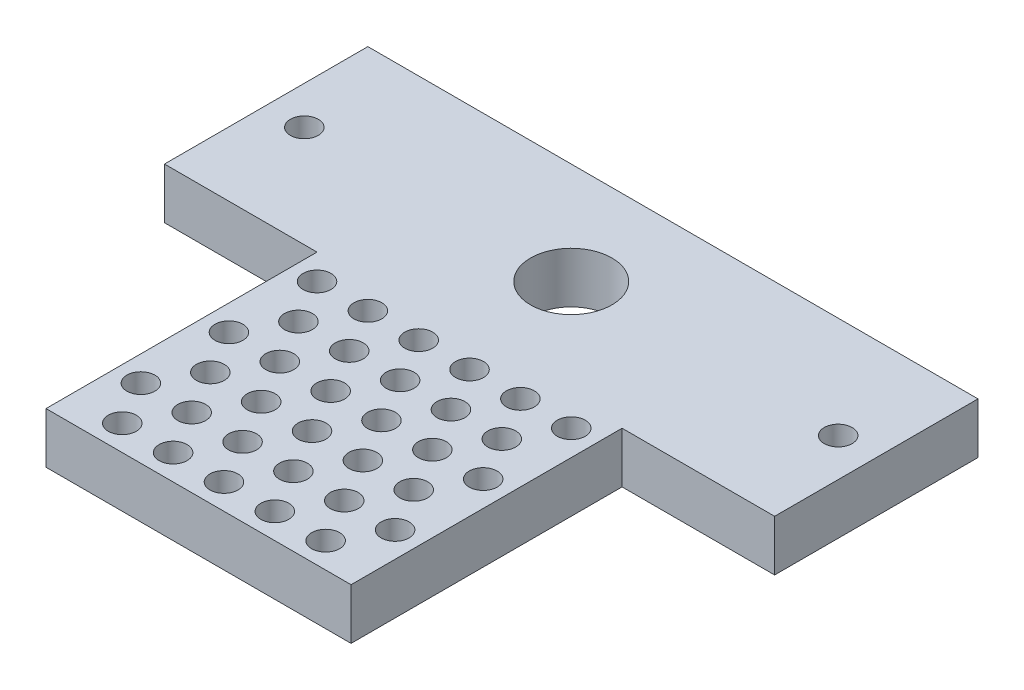
from build123d import *

# Parameters (mm, degrees)
SHUTTLE_W                = 6.096
SHUTTLE_H                = 2.032
SHUTTLE_EXTR_DEPTH       = 0.508
ELEC_BOUNDING_W          = 3.048
ELEC_BOUNDING_H          = 2.707704526
ELEC_BOUNDING_EXTR_DEPTH = 0.508
ELEC_ROW1_R              = 0.1397
ELEC_ROW1_EXTR_DEPTH     = 0.508
ELEC_ROW2_R              = 0.1397
ELEC_ROW2_EXTR_DEPTH     = 0.508
ELEC_ROW3_R              = 0.1397
ELEC_ROW3_EXTR_DEPTH     = 0.508
ELEC_ROW4_R              = 0.1397
ELEC_ROW4_EXTR_DEPTH     = 0.508
ELEC_ROW5_R              = 0.1397
ELEC_ROW5_EXTR_DEPTH     = 0.508
ELEC_MISC1_R             = 0.1397
ELEC_MISC1_EXTR_DEPTH    = 0.508
ELEC_MISC2_R             = 0.1397
ELEC_MISC2_EXTR_DEPTH    = 0.508
ELEC_ROW6_R              = 0.1397
ELEC_ROW6_EXTR_DEPTH     = 0.508
DRIVE_SCREW_R            = 0.4064
DRIVE_SCREW_EXTR_DEPTH   = 0.508
GUIDE_HOLES_R            = 0.1397
GUIDE_HOLES_EXTR_DEPTH   = 0.508


with BuildPart() as part:
    # shuttle → shuttle_extr (new body)
    with BuildSketch(Plane(origin=(0, 0, 0), x_dir=(1, 0, 0), z_dir=(0, 1, 0))):
        with Locations((-21.274651572, 3.469704526)):
            Rectangle(SHUTTLE_W, SHUTTLE_H)
    extrude(amount=-SHUTTLE_EXTR_DEPTH)

    # elec_bounding → elec_bounding_extr (add)
    with BuildSketch(Plane(origin=(0, 0, 0), x_dir=(1, 0, 0), z_dir=(0, 1, 0))):
        with Locations((-21.274651572, 1.099852263)):
            Rectangle(ELEC_BOUNDING_W, ELEC_BOUNDING_H)
    extrude(amount=-ELEC_BOUNDING_EXTR_DEPTH)

    # elec_row1 → elec_row1_extr (cut)
    with BuildSketch(Plane(origin=(0, 0, 0), x_dir=(1, 0, 0), z_dir=(0, 1, 0))):
        with Locations((-22.290651572, 0)):
            Circle(ELEC_ROW1_R)
        with Locations((-21.782651572, 0)):
            Circle(ELEC_ROW1_R)
        with Locations((-21.274651572, 0)):
            Circle(ELEC_ROW1_R)
        with Locations((-20.766651572, 0)):
            Circle(ELEC_ROW1_R)
        with Locations((-20.258651572, 0)):
            Circle(ELEC_ROW1_R)
    extrude(amount=-ELEC_ROW1_EXTR_DEPTH, mode=Mode.SUBTRACT)

    # elec_row2 → elec_row2_extr (cut)
    with BuildSketch(Plane(origin=(0, 0, 0), x_dir=(1, 0, 0), z_dir=(0, 1, 0))):
        with Locations((-22.036651572, 0.439940905)):
            Circle(ELEC_ROW2_R)
        with Locations((-21.528651572, 0.439940905)):
            Circle(ELEC_ROW2_R)
        with Locations((-21.020651572, 0.439940905)):
            Circle(ELEC_ROW2_R)
        with Locations((-20.512651572, 0.439940905)):
            Circle(ELEC_ROW2_R)
        with Locations((-20.004651572, 0.439940905)):
            Circle(ELEC_ROW2_R)
    extrude(amount=-ELEC_ROW2_EXTR_DEPTH, mode=Mode.SUBTRACT)

    # elec_row3 → elec_row3_extr (cut)
    with BuildSketch(Plane(origin=(0, 0, 0), x_dir=(1, 0, 0), z_dir=(0, 1, 0))):
        with Locations((-22.290651572, 0.87988181)):
            Circle(ELEC_ROW3_R)
        with Locations((-21.782651572, 0.87988181)):
            Circle(ELEC_ROW3_R)
        with Locations((-21.274651572, 0.87988181)):
            Circle(ELEC_ROW3_R)
        with Locations((-20.766651572, 0.87988181)):
            Circle(ELEC_ROW3_R)
        with Locations((-20.258651572, 0.87988181)):
            Circle(ELEC_ROW3_R)
    extrude(amount=-ELEC_ROW3_EXTR_DEPTH, mode=Mode.SUBTRACT)

    # elec_row4 → elec_row4_extr (cut)
    with BuildSketch(Plane(origin=(0, 0, 0), x_dir=(1, 0, 0), z_dir=(0, 1, 0))):
        with Locations((-22.036651572, 1.319822715)):
            Circle(ELEC_ROW4_R)
        with Locations((-21.528651572, 1.319822715)):
            Circle(ELEC_ROW4_R)
        with Locations((-21.020651572, 1.319822715)):
            Circle(ELEC_ROW4_R)
        with Locations((-20.512651572, 1.319822715)):
            Circle(ELEC_ROW4_R)
        with Locations((-20.004651572, 1.319822715)):
            Circle(ELEC_ROW4_R)
    extrude(amount=-ELEC_ROW4_EXTR_DEPTH, mode=Mode.SUBTRACT)

    # elec_row5 → elec_row5_extr (cut)
    with BuildSketch(Plane(origin=(0, 0, 0), x_dir=(1, 0, 0), z_dir=(0, 1, 0))):
        with Locations((-22.290651572, 1.75976362)):
            Circle(ELEC_ROW5_R)
        with Locations((-21.782651572, 1.75976362)):
            Circle(ELEC_ROW5_R)
        with Locations((-21.274651572, 1.75976362)):
            Circle(ELEC_ROW5_R)
        with Locations((-20.766651572, 1.75976362)):
            Circle(ELEC_ROW5_R)
        with Locations((-20.258651572, 1.75976362)):
            Circle(ELEC_ROW5_R)
    extrude(amount=-ELEC_ROW5_EXTR_DEPTH, mode=Mode.SUBTRACT)

    # elec_misc1 → elec_misc1_extr (cut)
    with BuildSketch(Plane(origin=(0, 0, 0), x_dir=(1, 0, 0), z_dir=(0, 1, 0))):
        with Locations((-22.544651572, 1.319822715)):
            Circle(ELEC_MISC1_R)
    extrude(amount=-ELEC_MISC1_EXTR_DEPTH, mode=Mode.SUBTRACT)

    # elec_misc2 → elec_misc2_extr (cut)
    with BuildSketch(Plane(origin=(0, 0, 0), x_dir=(1, 0, 0), z_dir=(0, 1, 0))):
        with Locations((-22.544651572, 0.439940905)):
            Circle(ELEC_MISC2_R)
    extrude(amount=-ELEC_MISC2_EXTR_DEPTH, mode=Mode.SUBTRACT)

    # elec_row6 → elec_row6_extr (cut)
    with BuildSketch(Plane(origin=(0, 0, 0), x_dir=(1, 0, 0), z_dir=(0, 1, 0))):
        with Locations((-20.004651572, 2.199704526)):
            Circle(ELEC_ROW6_R)
        with Locations((-20.512651572, 2.199704526)):
            Circle(ELEC_ROW6_R)
        with Locations((-21.020651572, 2.199704526)):
            Circle(ELEC_ROW6_R)
        with Locations((-21.528651572, 2.199704526)):
            Circle(ELEC_ROW6_R)
        with Locations((-22.036651572, 2.199704526)):
            Circle(ELEC_ROW6_R)
        with Locations((-22.544651572, 2.199704526)):
            Circle(ELEC_ROW6_R)
    extrude(amount=-ELEC_ROW6_EXTR_DEPTH, mode=Mode.SUBTRACT)

    # drive_screw → drive_screw_extr (cut)
    with BuildSketch(Plane(origin=(0, 0, 0), x_dir=(1, 0, 0), z_dir=(0, 1, 0))):
        with Locations((-21.274651572, 3.469704526)):
            Circle(DRIVE_SCREW_R)
    extrude(amount=-DRIVE_SCREW_EXTR_DEPTH, mode=Mode.SUBTRACT)

    # guide_holes → guide_holes_extr (cut)
    with BuildSketch(Plane(origin=(0, 0, 0), x_dir=(1, 0, 0), z_dir=(0, 1, 0))):
        with Locations((-23.941651572, 3.469704526)):
            Circle(GUIDE_HOLES_R)
        with Locations((-18.607651572, 3.469704526)):
            Circle(GUIDE_HOLES_R)
    extrude(amount=-GUIDE_HOLES_EXTR_DEPTH, mode=Mode.SUBTRACT)


solid = part.part
